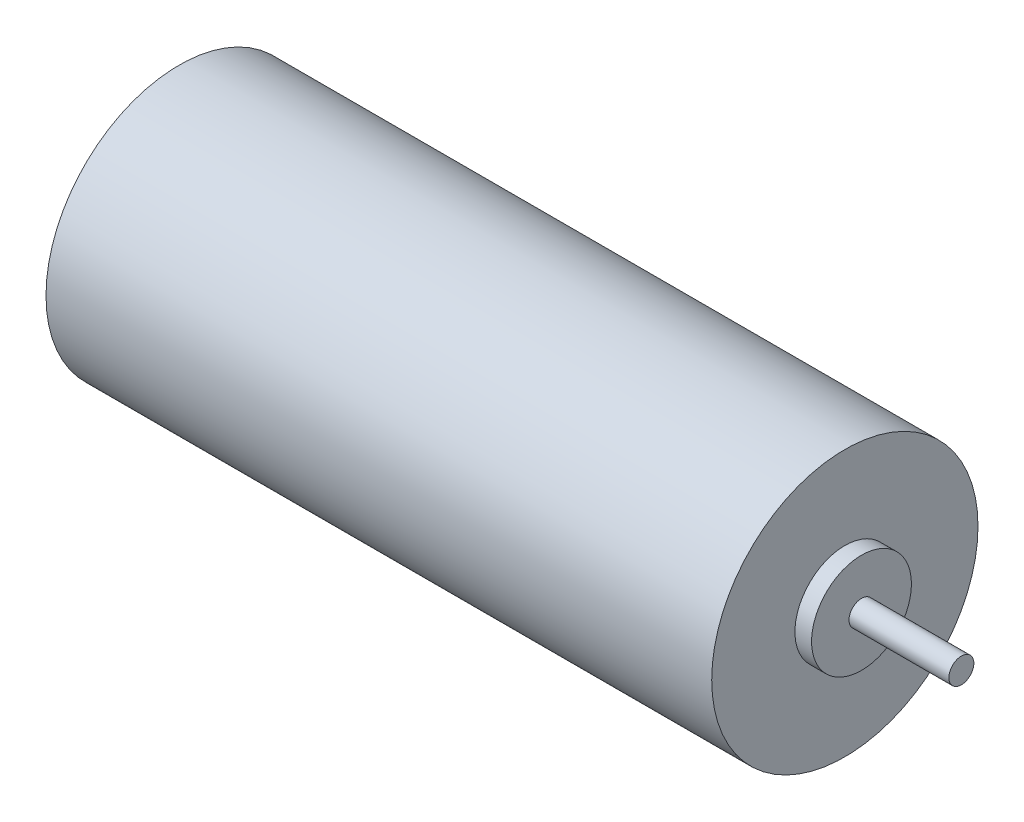
from build123d import *

# Parameters (mm, degrees)
SKETCH1_R           = 8
BOSS_EXTRUDE1_DEPTH = 40
SKETCH2_R           = 3
BOSS_EXTRUDE2_DEPTH = 1
SKETCH3_R           = 0.75
BOSS_EXTRUDE3_DEPTH = 6


with BuildPart() as part:
    # Sketch1 → Boss-Extrude1 (new body)
    with BuildSketch(Plane(origin=(0, 0, 0), x_dir=(0, 0, -1), z_dir=(1, 0, 0))):
        Circle(SKETCH1_R)
    extrude(amount=BOSS_EXTRUDE1_DEPTH)

    # Sketch2 → Boss-Extrude2 (add)
    with BuildSketch(Plane(origin=(40, 0, 0), x_dir=(0, 0, -1), z_dir=(1, 0, 0))):
        Circle(SKETCH2_R)
    extrude(amount=BOSS_EXTRUDE2_DEPTH)

    # Sketch3 → Boss-Extrude3 (add)
    with BuildSketch(Plane(origin=(41, 0, 0), x_dir=(0, 0, -1), z_dir=(1, 0, 0))):
        Circle(SKETCH3_R)
    extrude(amount=BOSS_EXTRUDE3_DEPTH)


solid = part.part
